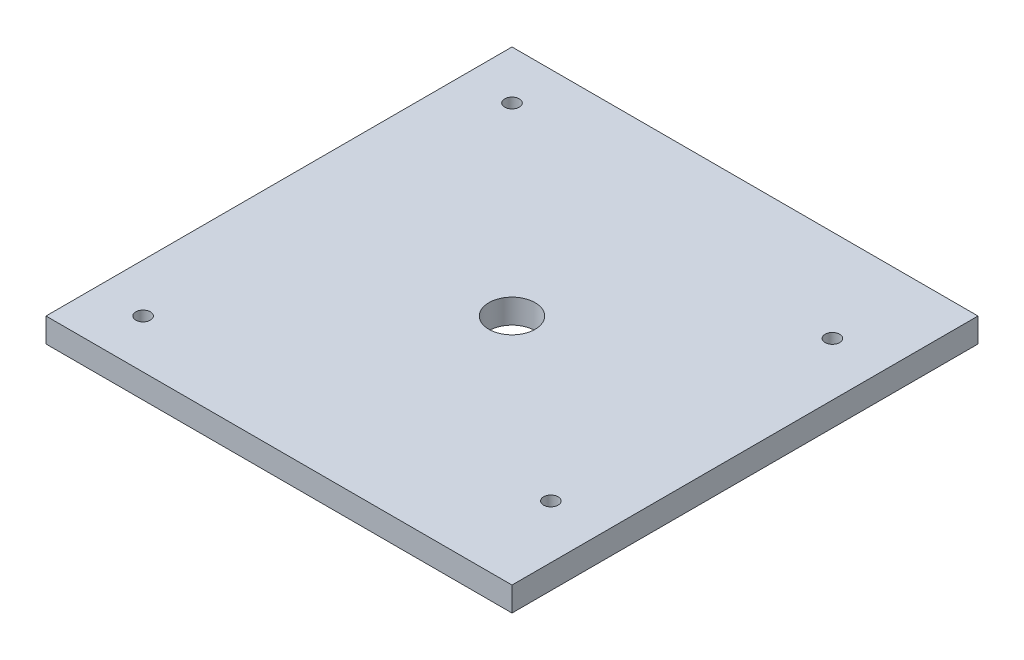
from build123d import *

# Parameters (mm, degrees)
SKETCH1_W           = 96
SKETCH1_H           = 96
SKETCH1_R           = 1.5
BOSS_EXTRUDE1_DEPTH = 5
SKETCH2_R           = 4.7625
CUT_EXTRUDE1_DEPTH  = 6


with BuildPart() as part:
    # Sketch1 → Boss-Extrude1 (new body)
    with BuildSketch(Plane(origin=(0, 0, 0), x_dir=(1, 0, 0), z_dir=(0, 1, 0))):
        with Locations((48, 48)):
            Rectangle(SKETCH1_W, SKETCH1_H)
        with Locations((10, 10)):
            Circle(SKETCH1_R, mode=Mode.SUBTRACT)
        with Locations((85, 19)):
            Circle(SKETCH1_R, mode=Mode.SUBTRACT)
        with Locations((85, 77)):
            Circle(SKETCH1_R, mode=Mode.SUBTRACT)
        with Locations((10, 86)):
            Circle(SKETCH1_R, mode=Mode.SUBTRACT)
    extrude(amount=BOSS_EXTRUDE1_DEPTH)

    # Sketch2 → Cut-Extrude1 (cut, through all)
    with BuildSketch(Plane(origin=(0, 5, 0), x_dir=(1, 0, 0), z_dir=(0, 1, 0))):
        with Locations((48, 48)):
            Circle(SKETCH2_R)
    extrude(amount=-CUT_EXTRUDE1_DEPTH, mode=Mode.SUBTRACT)


solid = part.part
